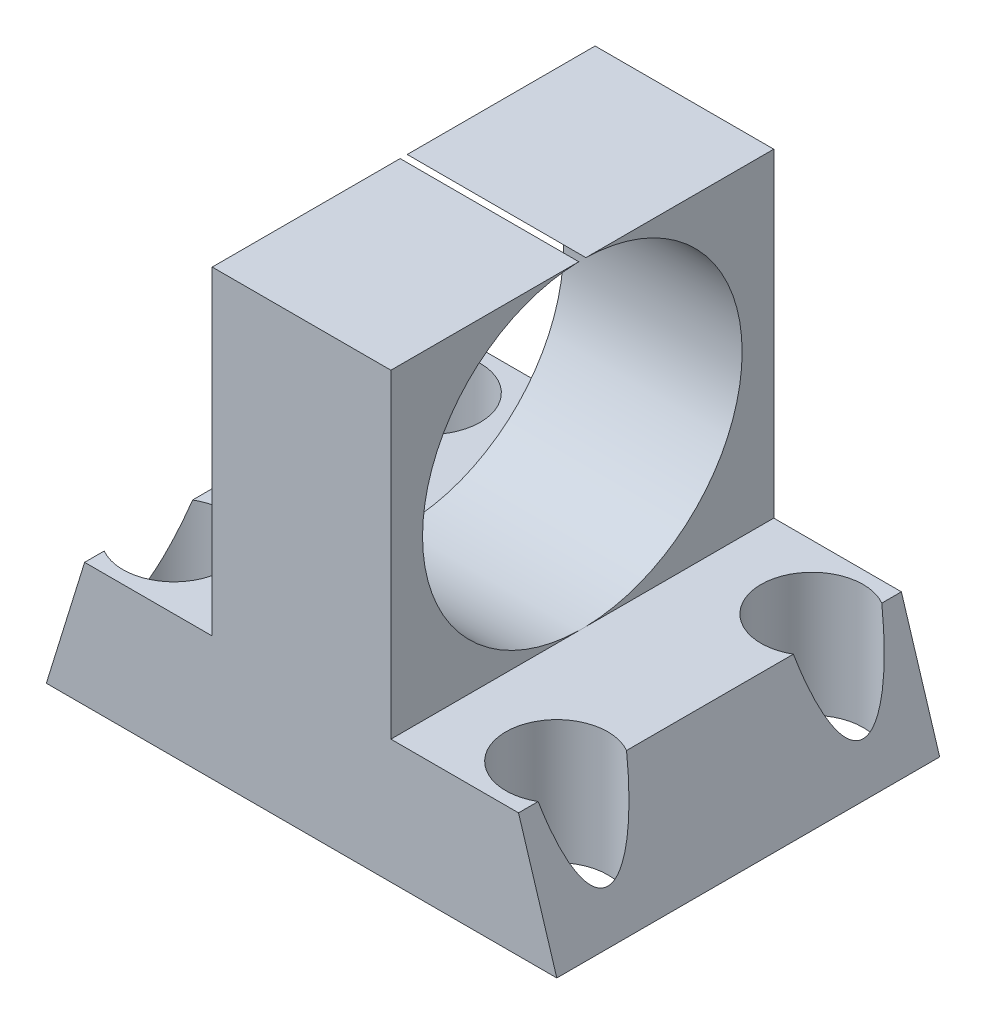
from build123d import *

# Parameters (mm, degrees)
EXTRUDE_1_DEPTH     = 15
SKETCH_2_R          = 6.260668565
CUT_EXTRUDE_1_DEPTH = 20
SKETCH_3_R          = 2
CUT_EXTRUDE_2_DEPTH = 20


with BuildPart() as part:
    # 草图1 → 凸台-拉伸1 (new body)
    with BuildSketch(Plane.XY):
        Polygon((-10.368613139, -4.854014599), (9.631386861, -4.854014599), (8.131386861, 0), (3.131386861, 0), (3.131386861, 12.518248175), (-3.868613139, 12.518248175), (-3.868613139, 0), (-8.868613139, 0), align=None)
    extrude(amount=EXTRUDE_1_DEPTH)

    # 草图2 → 切除-拉伸1 (cut)
    with BuildSketch(Plane(origin=(3.131386861, 0, 0), x_dir=(0, 0, -1), z_dir=(1, 0, 0))):
        with Locations((-7.5, 6.259124088)):
            Circle(SKETCH_2_R)
    extrude(amount=-CUT_EXTRUDE_1_DEPTH, mode=Mode.SUBTRACT)

    # 草图3 → 切除-拉伸2 (cut)
    with BuildSketch(Plane.XZ.offset(4.854014599)):
        with Locations(Location((-7.868613139, 12.5, 0), (0, 0, 270))):
            Circle(SKETCH_3_R)
        with Locations(Location((7.131386861, 12.5, 0), (0, 0, 270))):
            Circle(SKETCH_3_R)
        with Locations(Location((7.131386861, 2.5, 0), (0, 0, 270))):
            Circle(SKETCH_3_R)
        with Locations(Location((-7.868613139, 2.5, 0), (0, 0, 270))):
            Circle(SKETCH_3_R)
    extrude(amount=-CUT_EXTRUDE_2_DEPTH, mode=Mode.SUBTRACT)


solid = part.part
